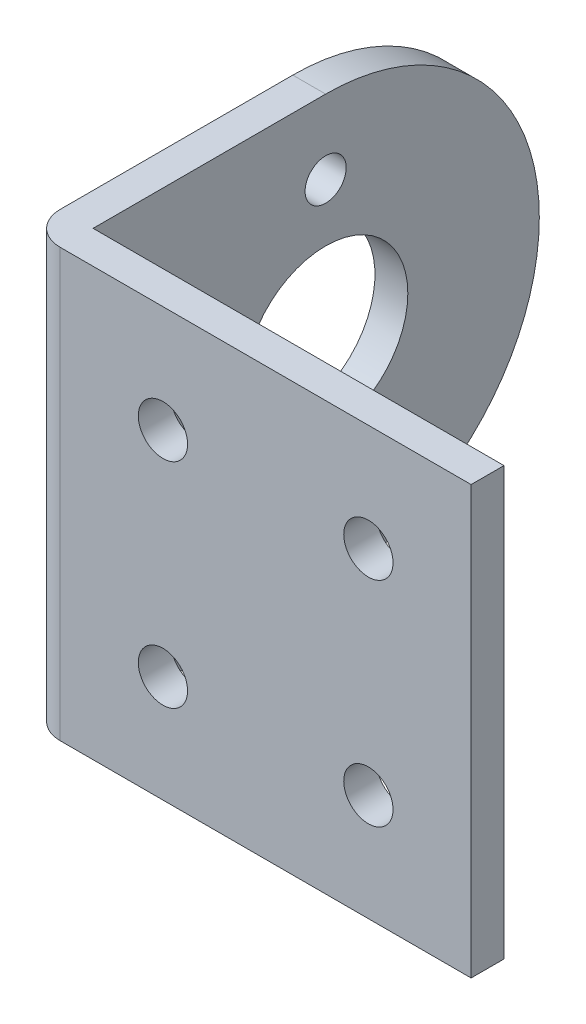
from build123d import *

# Parameters (mm, degrees)
ESQUISSE1_W             = 25
ESQUISSE1_H             = 26
ESQUISSE1_R             = 1.5
BOSS_EXTRU_1_DEPTH      = 2
BOSS_EXTRU_2_DEPTH      = 26
BOSS_EXTRU_3_DEPTH      = 2
ESQUISSE7_R             = 1.5
ENL_V_MAT_EXTRU_1_DEPTH = 3
ESQUISSE6_R             = 5
ENL_V_MAT_EXTRU_2_DEPTH = 28
ESQUISSE8_R             = 1.25
ENL_V_MAT_EXTRU_3_DEPTH = 28


with BuildPart() as part:
    # Esquisse1 → Boss.-Extru.1 (new body)
    with BuildSketch(Plane.XY):
        Rectangle(ESQUISSE1_W, ESQUISSE1_H)
        with Locations((-6.25, 6.5)):
            Circle(ESQUISSE1_R, mode=Mode.SUBTRACT)
        with Locations((6.25, 6.5)):
            Circle(ESQUISSE1_R, mode=Mode.SUBTRACT)
        with Locations((6.25, -6.5)):
            Circle(ESQUISSE1_R, mode=Mode.SUBTRACT)
        with Locations((-6.25, -6.5)):
            Circle(ESQUISSE1_R, mode=Mode.SUBTRACT)
    extrude(amount=BOSS_EXTRU_1_DEPTH)

    # Esquisse2 → Boss.-Extru.2 (add)
    with BuildSketch(Plane(origin=(0, 13, 0), x_dir=(1, 0, 0), z_dir=(0, 1, 0))):
        with BuildLine():
            Line((-12.5, -2), (12.5, -2))
            Line((12.5, -2), (12.5, 0))
            Line((12.5, 0), (-12.5, 0))
            Line((-12.5, 0), (-12.5, 14.15))
            Line((-12.5, 14.15), (-14.5, 14.15))
            Line((-14.5, 14.15), (-14.5, 0))
            ThreePointArc((-14.5, 0), (-13.914213562, -1.414213562), (-12.5, -2))
        make_face()
    extrude(amount=-BOSS_EXTRU_2_DEPTH)

    # Esquisse5 → Boss.-Extru.3 (add)
    with BuildSketch(Plane.ZY.offset(14.5)):
        with BuildLine():
            Line((-14.15, -13), (-14.15, 13))
            ThreePointArc((-14.15, 13), (-27.15, 0), (-14.15, -13))
        make_face()
    extrude(amount=-BOSS_EXTRU_3_DEPTH)

    # Esquisse7 → Enlèv. mat.-Extru.1 (cut, through all)
    with BuildSketch(Plane(origin=(0, 0, 0), x_dir=(-1, 0, 0), z_dir=(0, 0, -1))):
        with Locations((-6.25, -6.5)):
            Circle(ESQUISSE7_R)
        with Locations((6.25, -6.5)):
            Circle(ESQUISSE7_R)
        with Locations((6.25, 6.5)):
            Circle(ESQUISSE7_R)
        with Locations((-6.25, 6.5)):
            Circle(ESQUISSE7_R)
    extrude(amount=-ENL_V_MAT_EXTRU_1_DEPTH, mode=Mode.SUBTRACT)

    # Esquisse6 → Enlèv. mat.-Extru.2 (cut, through all)
    with BuildSketch(Plane.ZY.offset(14.5)):
        with Locations((-14.15, 0)):
            Circle(ESQUISSE6_R)
    extrude(amount=-ENL_V_MAT_EXTRU_2_DEPTH, mode=Mode.SUBTRACT)

    # Esquisse8 → Enlèv. mat.-Extru.3 (cut, through all)
    with BuildSketch(Plane.ZY.offset(14.5)):
        with Locations((-14.15, 8.5)):
            Circle(ESQUISSE8_R)
        with Locations((-14.15, -8.5)):
            Circle(ESQUISSE8_R)
    extrude(amount=-ENL_V_MAT_EXTRU_3_DEPTH, mode=Mode.SUBTRACT)


solid = part.part
